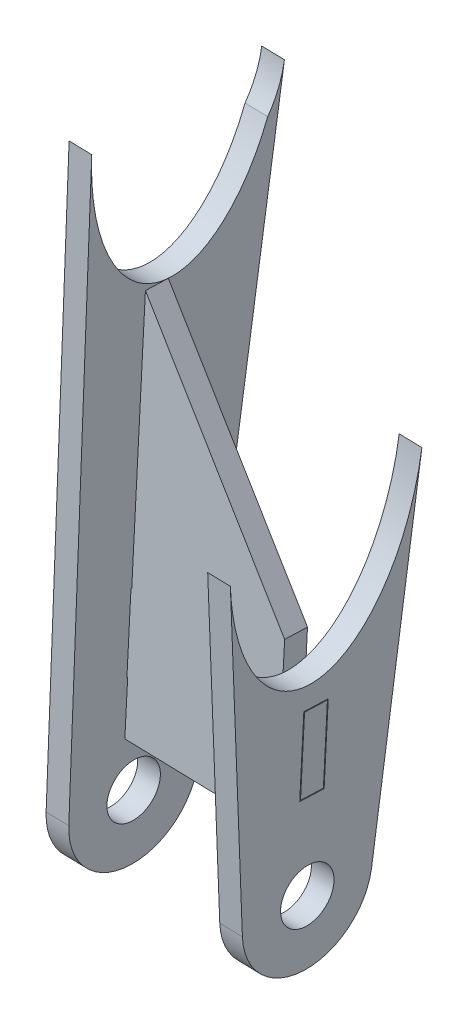
from build123d import *

# Parameters (mm, degrees)
SZKIC1_R                    = 3.5
DODANIE_WYCI_GNI_CIE1_DEPTH = 3
SZKIC3_R                    = 3.5
DODANIE_WYCI_GNI_CIE2_DEPTH = 3
DODANIE_WYCI_GNI_CIE3_DEPTH = 1.5
WYTNIJ_WYCI_GNI_CIE2_DEPTH  = 28.857347736
WYTNIJ_WYCI_GNI_CIE3_DEPTH  = 3


with BuildPart() as part:
    # Szkic1 → Dodanie-wyciągnięcie1 (new body)
    with BuildSketch(Plane(origin=(10.192666609, -0.209197232, 0.056926585), x_dir=(0.005582614, -0.000114579, -0.999984411), z_dir=(0.999773857, -0.020519647, 0.00558379))):
        with BuildLine():
            Line((-571.644797139, -36.876698077), (-569.215505996, -78.499745052))
            ThreePointArc((-569.215505996, -78.499745052), (-561.006887899, -86.499980329), (-552.29465683, -79.05134251))
            Line((-552.29465683, -79.05134251), (-546.635500505, -33.451067502))
            add(Edge.make_bspline(
                [(-546.635500505, -33.451067502), (-548.420830275, -47.836874114), (-555.450846412, -54.267572979), (-561.617780939, -53.532316767)],
                knots=[0.751052597, 0.751052597, 0.751052597, 0.751052597, 1, 1, 1, 1], degree=3, weights=[0.500008864, 0.501406417, 0.66807013, 1]))
            add(Edge.make_bspline(
                [(-561.617780939, -53.532316767), (-566.500920992, -52.950121667), (-571.015461445, -47.659625114), (-571.644797139, -36.876698077)],
                knots=[0, 0, 0, 0, 0.211755159, 0.211755159, 0.211755159, 0.211755159], degree=3, weights=[1, 0.717659787, 0.554893568, 0.511701343]))
        make_face()
        with Locations((-560.729946174, -78.004493099)):
            Circle(SZKIC1_R, mode=Mode.SUBTRACT)
    extrude(amount=-DODANIE_WYCI_GNI_CIE1_DEPTH)

    # Szkic8 → Wytnij-wyciągnięcie2 (cut, through all)
    with BuildSketch(Plane(origin=(10.192666609, -0.209197232, 0.056926585), x_dir=(0.005582614, -0.000114579, -0.999984411), z_dir=(0.999773857, -0.020519647, 0.00558379))):
        Polygon((-561.625338915, -56.363830635), (-561.957668986, -66.558415311), (-558.759367911, -66.662675725), (-558.42703784, -56.468091049), align=None)
    extrude(amount=-WYTNIJ_WYCI_GNI_CIE2_DEPTH, mode=Mode.SUBTRACT)


with BuildPart() as body_2:
    # Szkic3 → Dodanie-wyciągnięcie2 (new body)
    with BuildSketch(Plane(origin=(-12.802132105, 0.262754656, -0.071500588), x_dir=(0.005582614, -0.000114579, -0.999984411), z_dir=(0.999773857, -0.020519647, 0.00558379))):
        with BuildLine():
            Line((-569.228431577, -77.844037968), (-567.782050057, -1.236626489))
            add(Edge.make_bspline(
                [(-544.588187851, -8.501410275), (-553.261802258, -32.499980703), (-568.293763066, -28.339440284), (-567.782050057, -1.236626489)],
                knots=[0, 0, 0, 0, 0.978692843, 0.978692843, 0.978692843, 0.978692843], degree=3, weights=[1, 0.514675302, 0.504334413, 0.968977332]))
            add(Edge.make_bspline(
                [(-542.517178695, -2.989655167), (-542.77659051, -5.007707817), (-543.482930745, -6.876853891), (-544.588187851, -8.501410275)],
                knots=[0.307426475, 0.307426475, 0.307426475, 0.307426475, 1, 1, 1, 1], degree=3, weights=[0.976443899, 0.96660679, 0.974458824, 1]))
            Line((-542.517178695, -2.989655167), (-552.299314559, -79.088213807))
            ThreePointArc((-552.299314559, -79.088213807), (-561.352958544, -86.481630327), (-569.228431577, -77.844037968))
        make_face()
        with Locations((-560.729946174, -78.004493098)):
            Circle(SZKIC3_R, mode=Mode.SUBTRACT)
    extrude(amount=-DODANIE_WYCI_GNI_CIE2_DEPTH)

    # Szkic9 → Wytnij-wyciągnięcie3 (cut)
    with BuildSketch(Plane(origin=(-15.801453676, 0.324313598, -0.088251958), x_dir=(-0.005582614, 0.000114579, 0.999984411), z_dir=(-0.999773857, 0.020519647, -0.00558379))):
        Polygon((561.560176157, -54.364892463), (558.361875082, -54.469152877), (558.694205152, -64.663737554), (561.892506227, -64.559477139), align=None)
    extrude(amount=-WYTNIJ_WYCI_GNI_CIE3_DEPTH, mode=Mode.SUBTRACT)


with BuildPart() as body_3:
    # Szkic5 → Dodanie-wyciągnięcie3 (new body, symmetric)
    with BuildSketch(Plane(origin=(-2.739847058, 18.236911776, 557.585868102), x_dir=(0.020690962, 0.999254908, -0.032580872), z_dir=(0.004911082, -0.032689038, -0.999453505))):
        Polygon((-82.732434552, -15.805027871), (-82.732434552, -12.805027871), (-89.732434552, -12.805027871), (-89.732434552, 7.194972129), (-84.732434552, 7.194972129), (-84.732434552, 10.194972129), (-74.732434552, 10.194972129), (-74.732434552, 7.194972129), (-68.029811107, 7.194972129), (-38.868028096, -12.805027871), (-72.732434552, -12.805027871), (-72.732434552, -15.805027871), align=None)
    extrude(amount=DODANIE_WYCI_GNI_CIE3_DEPTH, both=True)


solid = Compound([part.part, body_2.part, body_3.part])
